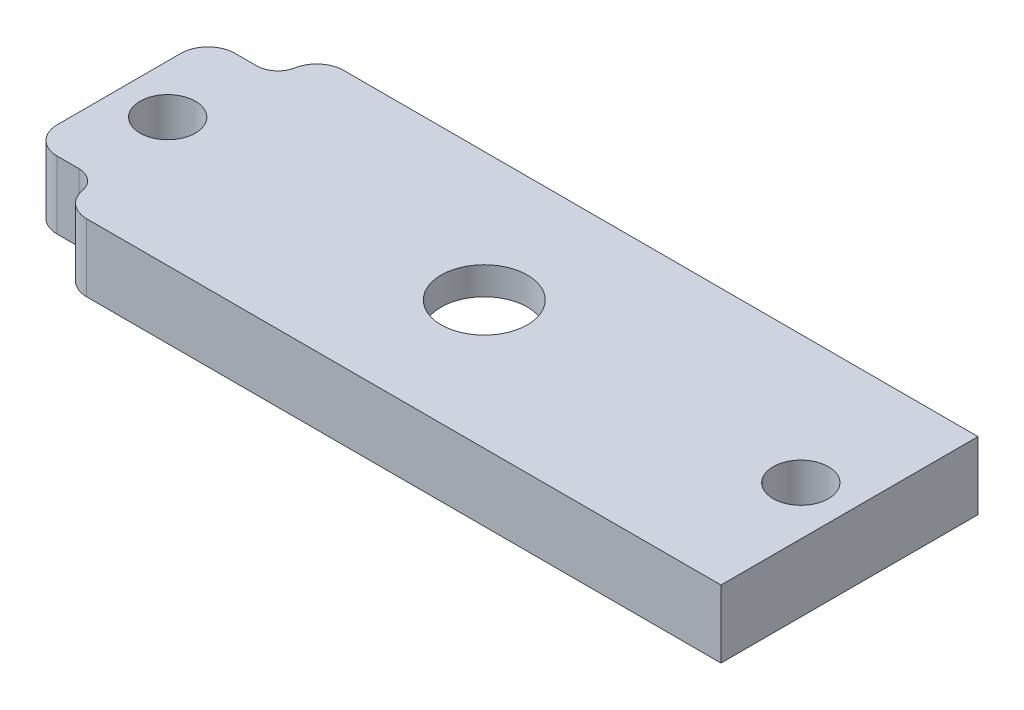
from build123d import *

# Parameters (mm, degrees)
SKETCH2_W           = 68.58
SKETCH2_H           = 24.13
SKETCH2_R           = 2.6
BOSS_EXTRUDE1_DEPTH = 6.35
CUT_EXTRUDE1_DEPTH  = 7.35
FILLET3_R           = 2.54
SKETCH4_R           = 4.05
CUT_EXTRUDE2_DEPTH  = 7.3500001


with BuildPart() as part:
    # Sketch2 → Boss-Extrude1 (new body)
    with BuildSketch(Plane(origin=(0, 0, 0), x_dir=(1, 0, 0), z_dir=(0, 1, 0))):
        with Locations((34.29, 12.065)):
            Rectangle(SKETCH2_W, SKETCH2_H)
        with Locations((4.57, 12.065)):
            Circle(SKETCH2_R, mode=Mode.SUBTRACT)
        with Locations((64.01, 12.065)):
            Circle(SKETCH2_R, mode=Mode.SUBTRACT)
    extrude(amount=BOSS_EXTRUDE1_DEPTH)

    # Sketch3 → Cut-Extrude1 (cut, through all)
    with BuildSketch(Plane(origin=(0, 6.35, 0), x_dir=(1, 0, 0), z_dir=(0, 1, 0))):
        with BuildLine():
            Line((4.57, 3.715), (0, 3.715))
            Line((0, 3.715), (0, 0))
            Line((0, 0), (6.57, 0))
            Line((6.57, 0), (6.57, 1.715))
            ThreePointArc((6.57, 1.715), (5.984213562, 3.129213562), (4.57, 3.715))
        make_face()
        with BuildLine():
            ThreePointArc((4.57, 20.415), (5.984213562, 21.000786438), (6.57, 22.415))
            Line((6.57, 22.415), (6.57, 24.13))
            Line((6.57, 24.13), (0, 24.13))
            Line((0, 24.13), (0, 20.415))
            Line((0, 20.415), (4.57, 20.415))
        make_face()
    extrude(amount=-CUT_EXTRUDE1_DEPTH, mode=Mode.SUBTRACT)

    # Fillet3
    fillet3_edges = [part.edges().sort_by_distance(p)[0] for p in [
        (6.57, 3.175, 0),
        (0, 3.175, -3.715),
        (0, 3.175, -20.415),
        (6.57, 3.175, -24.13),
    ]]
    fillet(fillet3_edges, radius=FILLET3_R)

    # Sketch4 → Cut-Extrude2 (cut, through all)
    with BuildSketch(Plane(origin=(0, 6.35, 0), x_dir=(1, 0, 0), z_dir=(0, 1, 0))):
        with Locations((34.29, 12.065)):
            Circle(SKETCH4_R)
    extrude(amount=-CUT_EXTRUDE2_DEPTH, mode=Mode.SUBTRACT)

    # Sketch8 one side → Cut-Revolve6 (revolve, cut)
    with BuildSketch(Plane(origin=(34.29, 0, 0), x_dir=(0, 0, -1), z_dir=(1, 0, 0))):
        with BuildLine():
            Line((12.065, 0), (22.13, 0))
            ThreePointArc((22.13, 0), (17.5473974, 3.215969501), (12.065, 4.35))
            Line((12.065, 4.35), (12.065, 0))
        make_face()
    revolve(axis=Axis((34.29, 6.35, -12.065), (0, -1, 0)), mode=Mode.SUBTRACT)


solid = part.part
